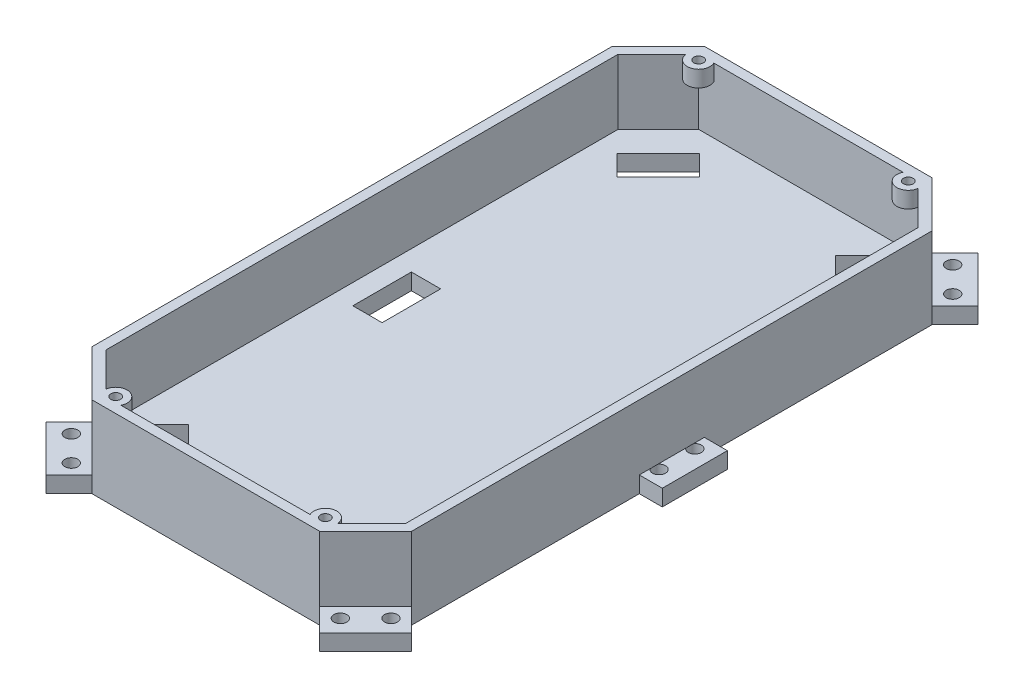
from build123d import *

# Parameters (mm, degrees)
BOSS_EXTRUDE1_DEPTH = 5
BOSS_EXTRUDE3_DEPTH = 20
SKETCH5_W           = 9
SKETCH5_H           = 18
CUT_EXTRUDE3_DEPTH  = 20
SKETCH6_R           = 3.5
SKETCH6_R_2         = 1.5
BOSS_EXTRUDE4_DEPTH = 5
SKETCH7_R           = 2
CUT_EXTRUDE4_DEPTH  = 5


with BuildPart() as part:
    # Sketch1 → Boss-Extrude1 (new body)
    with BuildSketch(Plane(origin=(0, 0, 0), x_dir=(1, 0, 0), z_dir=(0, 1, 0))):
        Polygon((14.142135624, 0), (84.142135624, 0), (91.213203436, -7.071067812), (98.284271247, 0), (105.355339059, 7.071067812), (98.284271247, 14.142135624), (98.284271247, 84.142135624), (105.355339059, 84.142135624), (105.355339059, 104.142135624), (98.284271247, 104.142135624), (98.284271247, 174.142135624), (105.355339059, 181.213203436), (98.284271247, 188.284271247), (91.213203436, 195.355339059), (84.142135624, 188.284271247), (14.142135624, 188.284271247), (7.071067812, 195.355339059), (0, 188.284271247), (-7.071067812, 181.213203436), (0, 174.142135624), (0, 104.142135624), (-7.071067812, 104.142135624), (-7.071067812, 84.142135624), (0, 84.142135624), (0, 14.142135624), (-7.071067812, 7.071067812), (0, 0), (7.071067812, -7.071067812), align=None)
    extrude(amount=BOSS_EXTRUDE1_DEPTH)

    # Sketch4 → Boss-Extrude3 (add)
    with BuildSketch(Plane(origin=(0, 5, 0), x_dir=(1, 0, 0), z_dir=(0, 1, 0))):
        Polygon((0, 174.142135624), (14.142135624, 188.284271247), (84.142135624, 188.284271247), (98.284271247, 174.142135624), (98.284271247, 14.142135624), (84.142135624, 0), (14.142135624, 0), (0, 14.142135624), align=None)
        Polygon((3, 15.384776311), (3, 172.899494937), (15.384776311, 185.284271247), (82.899494937, 185.284271247), (95.284271247, 172.899494937), (95.284271247, 15.384776311), (82.899494937, 3), (15.384776311, 3), align=None, mode=Mode.SUBTRACT)
    extrude(amount=BOSS_EXTRUDE3_DEPTH)

    # Sketch5 → Cut-Extrude3 (cut)
    with BuildSketch(Plane(origin=(0, 5, 0), x_dir=(1, 0, 0), z_dir=(0, 1, 0))):
        Polygon((70, 15.556349186), (76.363961031, 9.192388155), (82.727922061, 15.556349186), (89.091883092, 21.920310217), (82.727922061, 28.284271247), align=None)
        Polygon((21.920310217, 9.192388155), (15.556349186, 15.556349186), (9.192388155, 21.920310217), (15.556349186, 28.284271247), (28.284271247, 15.556349186), align=None)
        with Locations((13.702828803, 94.142135624)):
            Rectangle(SKETCH5_W, SKETCH5_H)
        with Locations((84.581442444, 94.142135624)):
            Rectangle(SKETCH5_W, SKETCH5_H)
        Polygon((76.363961031, 179.091883092), (82.727922061, 172.727922061), (89.091883092, 166.363961031), (82.727922061, 160), (70, 172.727922061), align=None)
        Polygon((15.556349186, 160), (28.284271247, 172.727922061), (21.920310217, 179.091883092), (15.556349186, 172.727922061), (9.192388155, 166.363961031), align=None)
    extrude(amount=-CUT_EXTRUDE3_DEPTH, mode=Mode.SUBTRACT)

    # Sketch6 → Boss-Extrude4 (add)
    with BuildSketch(Plane(origin=(0, 25, 0), x_dir=(1, 0, 0), z_dir=(0, 1, 0))):
        with Locations((16.907704548, 183.761343011)):
            Circle(SKETCH6_R)
        with Locations((16.907704548, 183.761343011)):
            Circle(SKETCH6_R_2, mode=Mode.SUBTRACT)
        with Locations((81.3765667, 183.761343011)):
            Circle(SKETCH6_R)
        with Locations((81.3765667, 183.761343011)):
            Circle(SKETCH6_R_2, mode=Mode.SUBTRACT)
        with Locations((81.3765667, 4.522928237)):
            Circle(SKETCH6_R)
        with Locations((81.3765667, 4.522928237)):
            Circle(SKETCH6_R_2, mode=Mode.SUBTRACT)
        with Locations((16.907704548, 4.522928237)):
            Circle(SKETCH6_R)
        with Locations((16.907704548, 4.522928237)):
            Circle(SKETCH6_R_2, mode=Mode.SUBTRACT)
    extrude(amount=-BOSS_EXTRUDE4_DEPTH)

    # Sketch7 → Cut-Extrude4 (cut)
    with BuildSketch(Plane(origin=(0, 5, 0), x_dir=(1, 0, 0), z_dir=(0, 1, 0))):
        with Locations((7.778174593, 188.284271247)):
            Circle(SKETCH7_R)
        with Locations((0, 180.506096654)):
            Circle(SKETCH7_R)
        with Locations((90.506096654, 188.284271247)):
            Circle(SKETCH7_R)
        with Locations((98.284271247, 180.506096654)):
            Circle(SKETCH7_R)
        with Locations((99.855339059, 99.642135624)):
            Circle(SKETCH7_R)
        with Locations((99.855339059, 88.642135624)):
            Circle(SKETCH7_R)
        with Locations((98.284271247, 7.778174593)):
            Circle(SKETCH7_R)
        with Locations((90.506096654, 0)):
            Circle(SKETCH7_R)
        with Locations((7.778174593, 0)):
            Circle(SKETCH7_R)
        with Locations((0, 7.778174593)):
            Circle(SKETCH7_R)
        with Locations((-1.571067812, 88.642135624)):
            Circle(SKETCH7_R)
        with Locations((-1.571067812, 99.642135624)):
            Circle(SKETCH7_R)
    extrude(amount=-CUT_EXTRUDE4_DEPTH, mode=Mode.SUBTRACT)


solid = part.part
